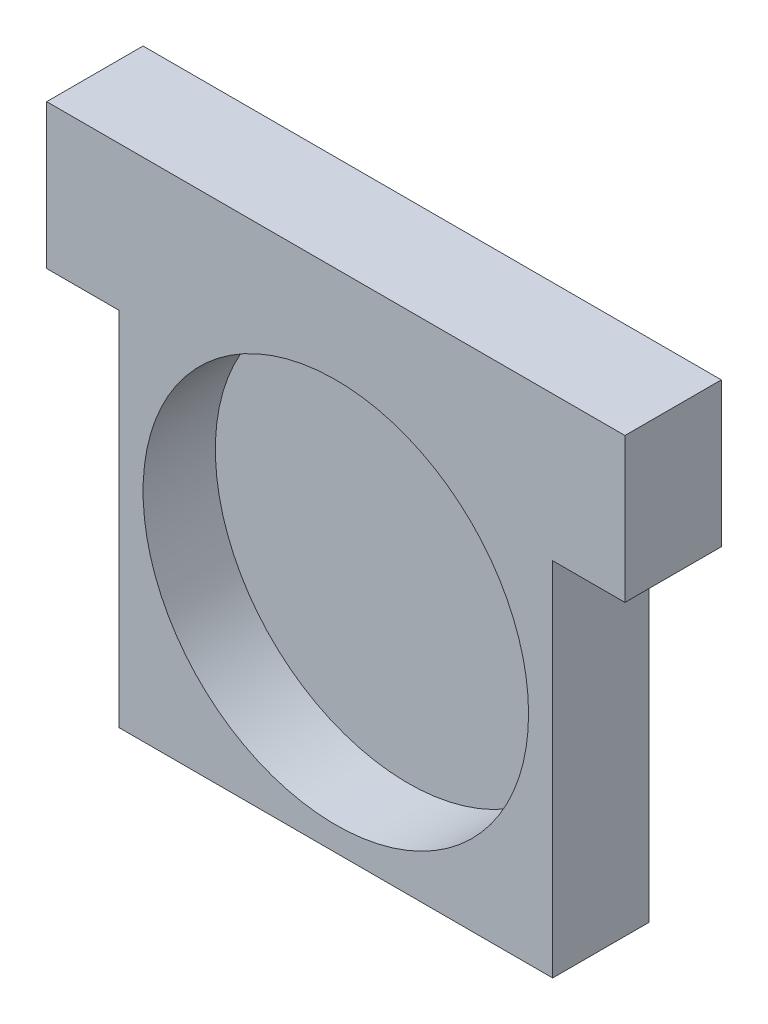
from build123d import *

# Parameters (mm, degrees)
SKETCH1_W               = 76.2
SKETCH1_H               = 76.2
BOSS_EXTRUDE1_DEPTH     = 12.7
SKETCH2_R               = 25.4
CUT_EXTRUDE1_DEPTH      = 9.525
CUT_EXTRUDE3_DEPTH      = 1
CUT_EXTRUDE3_DEPTH_BACK = 13.7


with BuildPart() as part:
    # Sketch1 → Boss-Extrude1 (new body)
    with BuildSketch(Plane.XY):
        Rectangle(SKETCH1_W, SKETCH1_H)
    extrude(amount=BOSS_EXTRUDE1_DEPTH)

    # Sketch2 → Cut-Extrude1 (cut)
    with BuildSketch(Plane.XY.offset(12.7)):
        Circle(SKETCH2_R)
    extrude(amount=-CUT_EXTRUDE1_DEPTH, mode=Mode.SUBTRACT)

    # Sketch3 → Cut-Extrude3 (cut, two sides)
    with BuildSketch(Plane.XY.offset(12.7)) as cut_extrude3_sk:
        Polygon((238.6, 19.05), (38.1, 19.05), (28.575, 19.05), (28.575, -28.575), (-28.575, -28.575), (-28.575, 19.05), (-38.1, 19.05), (-238.6, 19.05), (-238.6, -381.95), (238.6, -381.95), align=None)
    extrude(amount=CUT_EXTRUDE3_DEPTH, mode=Mode.SUBTRACT)
    extrude(cut_extrude3_sk.sketch, amount=-CUT_EXTRUDE3_DEPTH_BACK, mode=Mode.SUBTRACT)


solid = part.part
